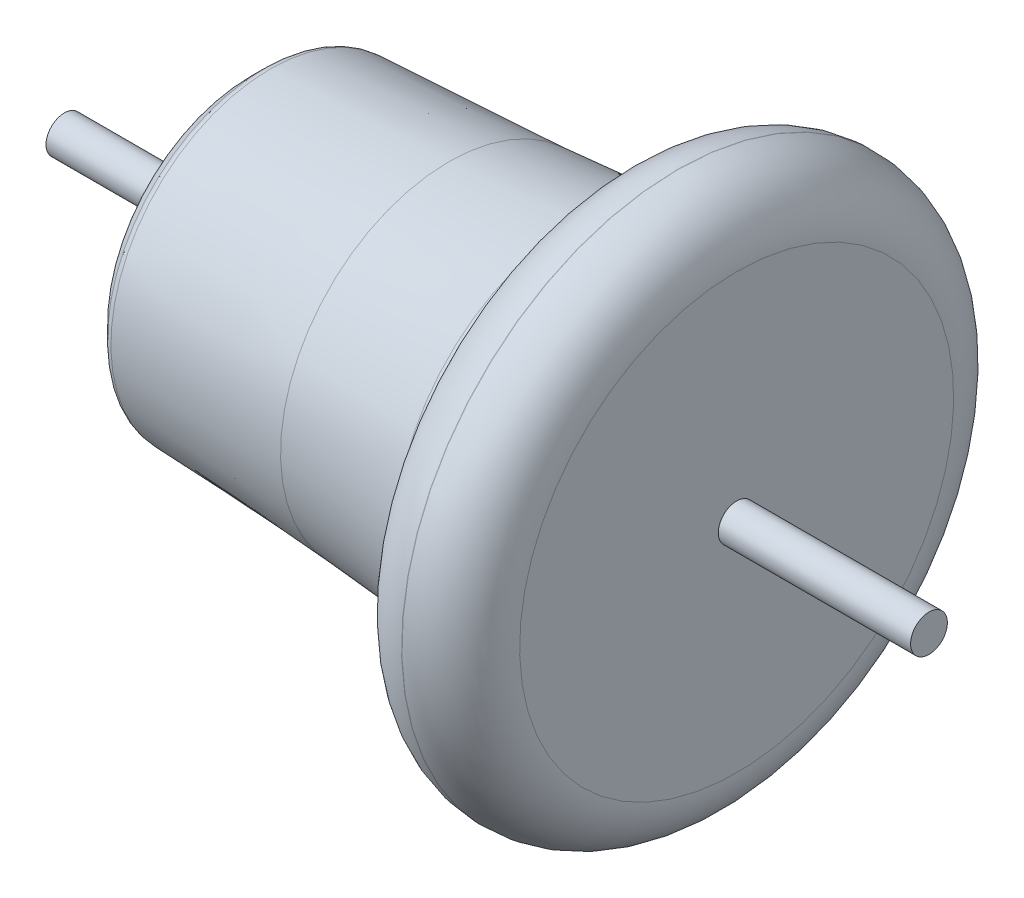
from build123d import *

# Parameters (mm, degrees)
SKETCH3_R                = 5
BOSS_EXTRUDE1_DEPTH      = 50
BOSS_EXTRUDE1_DEPTH_BACK = 185


with BuildPart() as part:
    # Sketch2 → Revolve1 (revolve)
    with BuildSketch(Plane.XY):
        with BuildLine():
            Line((-126.767029403, 81.676904789), (-78.228933631, 79.25))
            ThreePointArc((-78.228933631, 79.25), (-60.619483805, 77.84878425), (-43.123035518, 75.413537626))
            ThreePointArc((-43.123035518, 75.413537626), (-41.060447751, 74.831340884), (-39.169286378, 73.823010577))
            ThreePointArc((-39.169286378, 73.823010577), (-35.312933401, 70.206346657), (-32.754159078, 65.579858771))
            Line((-32.754159078, 65.579858771), (-32.056761325, 63.663774193))
            ThreePointArc((-32.056761325, 63.663774193), (-31.860334358, 63.066262055), (-31.701859109, 62.457583237))
            ThreePointArc((-31.701859109, 62.457583237), (-26.081952508, 53.496427146), (-16.098933631, 50))
            Line((-16.098933631, 50), (-16, 50))
            ThreePointArc((-16, 50), (-4.686291501, 54.686291501), (0, 66))
            Line((0, 66), (0, 78.5))
            Line((0, 78.5), (0, 125))
            Line((0, 125), (-132.728933631, 125))
            Line((-132.728933631, 125), (-132.728933631, 97.760533906))
            Line((-132.728933631, 97.760533906), (-132.728933631, 87.760533906))
            ThreePointArc((-132.728933631, 87.760533906), (-132.538632462, 86.803825325), (-131.996700584, 85.992766953))
            Line((-131.996700584, 85.992766953), (-128.409952314, 82.406018683))
            ThreePointArc((-128.409952314, 82.406018683), (-127.656283908, 81.888702675), (-126.767029403, 81.676904789))
        make_face()
    revolve(axis=Axis((0, 125, 0), (-1, 0, 0)))

    # Sketch3 → Boss-Extrude1 (add, two sides)
    with BuildSketch(Plane.ZY.offset(132.728933631)) as boss_extrude1_sk:
        with Locations((0, 125)):
            Circle(SKETCH3_R)
    extrude(amount=BOSS_EXTRUDE1_DEPTH)
    extrude(boss_extrude1_sk.sketch, amount=-BOSS_EXTRUDE1_DEPTH_BACK)


solid = part.part
